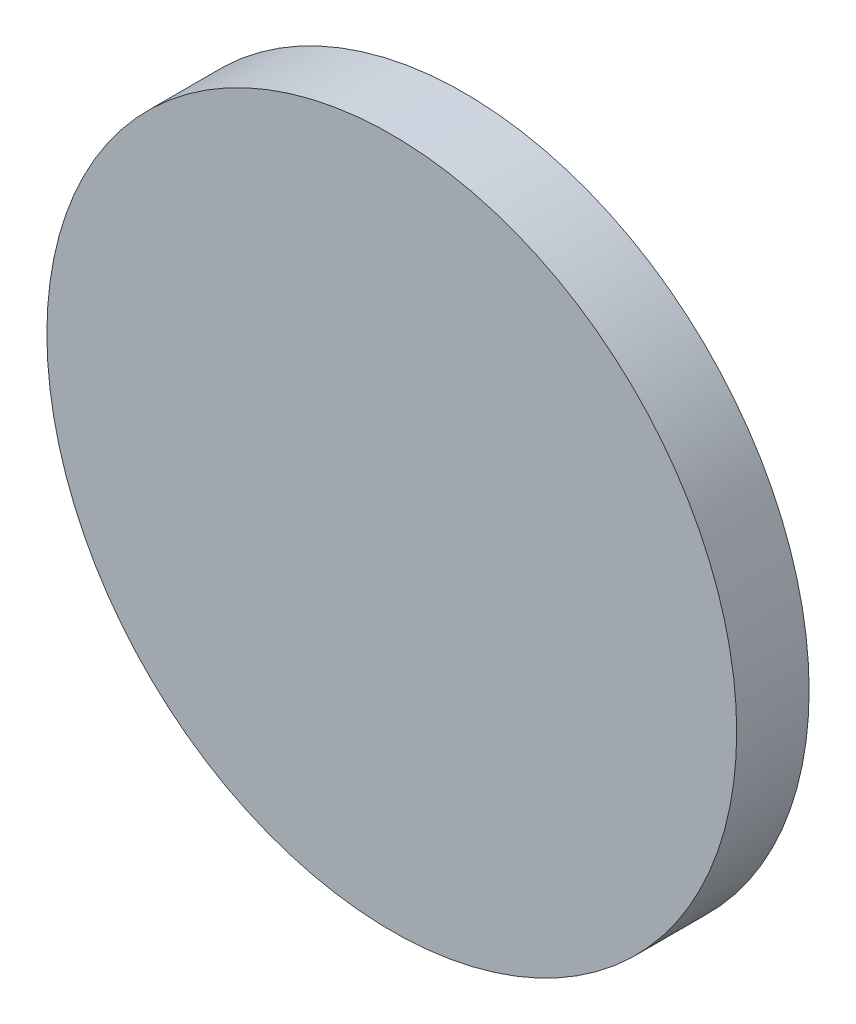
from build123d import *

# Parameters (mm, degrees)
SKETCH_1_R      = 19.05
EXTRUDE_1_DEPTH = 4


with BuildPart() as part:
    # 草图1 → 凸台-拉伸1 (new body)
    with BuildSketch(Plane.XY):
        Circle(SKETCH_1_R)
    extrude(amount=EXTRUDE_1_DEPTH)


solid = part.part
